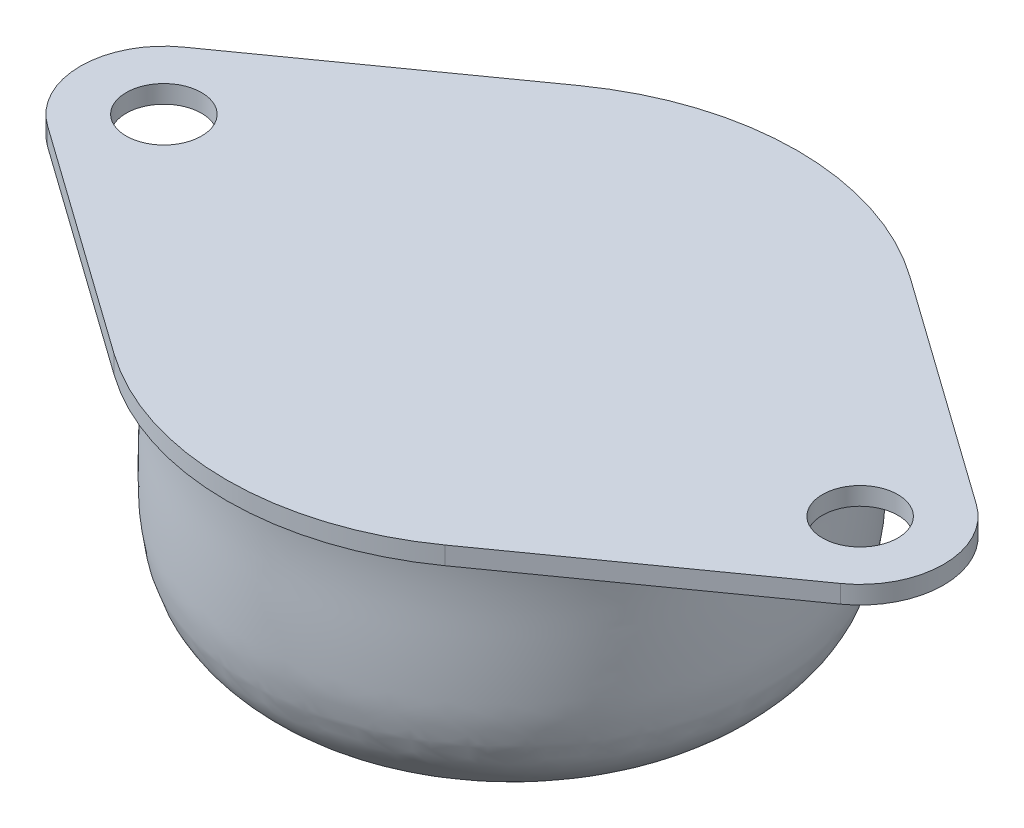
from build123d import *

# Parameters (mm, degrees)
SKETCH_2_R      = 2.1
EXTRUDE_1_DEPTH = 1


with BuildPart() as part:
    # 草图1 → 旋转1 (revolve)
    with BuildSketch(Plane.XY):
        with BuildLine():
            Line((14.944585174, 15.701905636), (0, 15.701905636))
            Line((0, 15.701905636), (0, -3.298094364))
            add(Edge.make_bspline(
                [(0, -3.298094364), (0.706455528, -3.332616299), (1.691072276, -3.219064863), (2.773175522, -2.870028275), (3.305020932, -2.665292125), (3.682415706, -2.517038895), (4.050641345, -2.355189766), (4.416695399, -2.20481684), (4.77817462, -2.003706717), (5.099926424, -1.754542973), (5.469244366, -1.550129904), (5.861768452, -1.245065409), (6.265016456, -0.923290365), (6.630974372, -0.544071897), (6.924875069, -0.139959882), (7.370604687, 0.048686033), (7.772218261, 0.161143877), (8.158981876, 0.24790247), (8.578399204, 0.358534367), (9.10951982, 0.547037122), (9.69818302, 0.72066457), (10.259773085, 0.91104592), (10.747610732, 1.028094825), (11.160281011, 1.214814977), (11.564815316, 1.481178609), (12.000197559, 1.680416472), (12.456348878, 1.97889325), (12.887671936, 2.339764988), (13.291414369, 2.770380198), (13.622058348, 3.171561468), (13.87545394, 3.574212032), (14.104629888, 3.983119622), (14.24807752, 4.50808303), (14.453255803, 4.977984441), (14.55328951, 5.613547364), (14.688797752, 6.352898821), (14.744580933, 7.850347198), (14.739662401, 9.917386792), (14.610748365, 12.725417472), (14.745577946, 14.655065366), (14.944585174, 15.701905636)],
                knots=[0, 0, 0, 0, 0.074980327, 0.104145363, 0.120682551, 0.135565386, 0.147239076, 0.163438876, 0.177614949, 0.191043322, 0.206610736, 0.222342481, 0.243822524, 0.261329251, 0.278460385, 0.295787667, 0.311179453, 0.323053348, 0.337863831, 0.357273022, 0.382918323, 0.403098398, 0.420289185, 0.436132056, 0.450933537, 0.471701704, 0.4868637, 0.508750883, 0.531302671, 0.549552014, 0.563884853, 0.581874699, 0.599060538, 0.621525796, 0.636019375, 0.667207468, 0.701413253, 0.794955071, 0.88706401, 1, 1, 1, 1], degree=3))
        make_face()
    revolve(axis=Axis((0, -3.298094364, 0), (0, 1, 0)))

    # 草图2 → 凸台-拉伸1 (add)
    with BuildSketch(Plane(origin=(0, 15.701905636, 0), x_dir=(1, 0, 0), z_dir=(0, 1, 0))):
        with BuildLine():
            Line((9.220360825, 12.953568862), (22.096520619, 3.788307875))
            ThreePointArc((22.096520619, 3.788307875), (24.05, 0), (22.096520619, -3.788307875))
            Line((22.096520619, -3.788307875), (9.220360825, -12.953568862))
            ThreePointArc((9.220360825, -12.953568862), (0, -15.9), (-9.220360825, -12.953568862))
            Line((-9.220360825, -12.953568862), (-22.096520619, -3.788307875))
            ThreePointArc((-22.096520619, -3.788307875), (-24.05, 0), (-22.096520619, 3.788307875))
            Line((-22.096520619, 3.788307875), (-9.220360825, 12.953568862))
            ThreePointArc((-9.220360825, 12.953568862), (0, 15.9), (9.220360825, 12.953568862))
        make_face()
        with Locations((19.4, 0)):
            Circle(SKETCH_2_R, mode=Mode.SUBTRACT)
        with Locations((-19.4, 0)):
            Circle(SKETCH_2_R, mode=Mode.SUBTRACT)
    extrude(amount=-EXTRUDE_1_DEPTH)


solid = part.part
